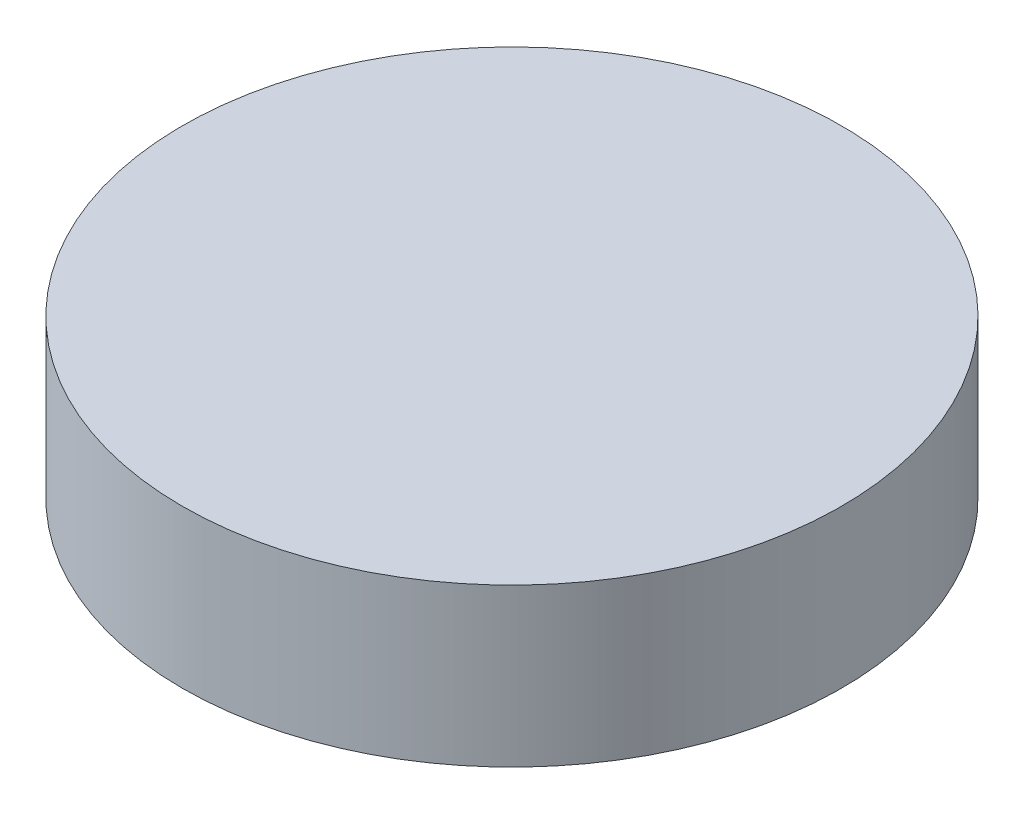
from build123d import *

# Parameters (mm, degrees)
SKETCH1_R           = 6.6378
BOSS_EXTRUDE1_DEPTH = 3.175


with BuildPart() as part:
    # Sketch1 → Boss-Extrude1 (new body)
    with BuildSketch(Plane(origin=(0, 0, 0), x_dir=(1, 0, 0), z_dir=(0, 1, 0))):
        Circle(SKETCH1_R)
    extrude(amount=BOSS_EXTRUDE1_DEPTH)


solid = part.part
